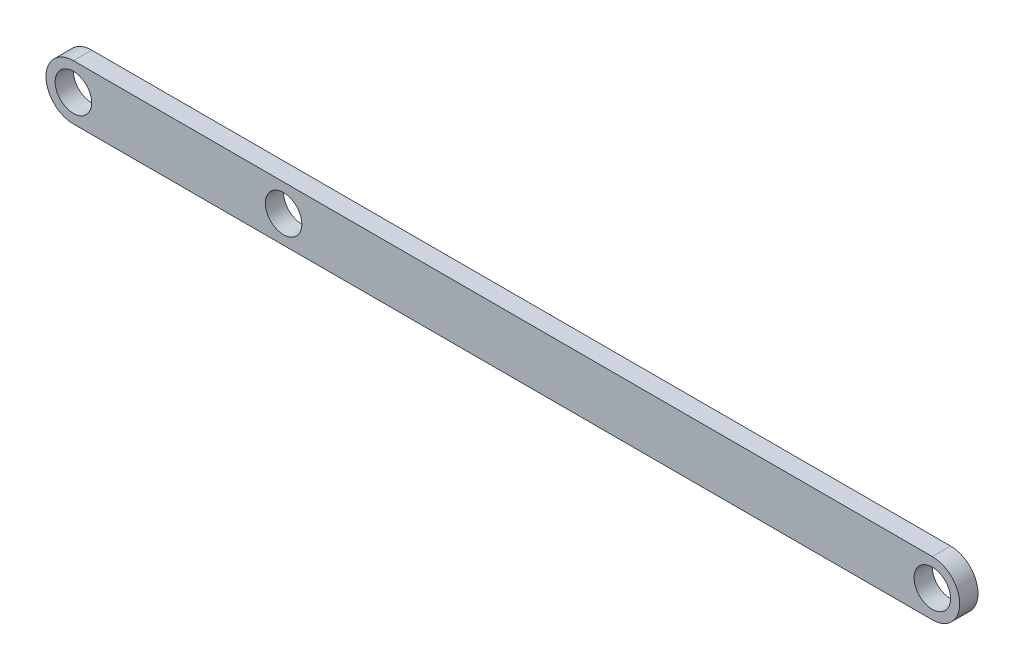
from build123d import *

# Parameters (mm, degrees)
SKETCH3_W           = 250
SKETCH3_H           = 15
BOSS_EXTRUDE4_DEPTH = 5
SKETCH7_R           = 5
CUT_EXTRUDE3_DEPTH  = 5
SKETCH8_R           = 5
CUT_EXTRUDE5_DEPTH  = 6


with BuildPart() as part:
    # Sketch3 → Boss-Extrude4 (new body)
    with BuildSketch(Plane.XY):
        with Locations((-125, 7.5)):
            Rectangle(SKETCH3_W, SKETCH3_H)
    extrude(amount=BOSS_EXTRUDE4_DEPTH)

    # Sketch7 → Cut-Extrude3 (cut)
    with BuildSketch(Plane.XY.offset(5)):
        with BuildLine():
            Line((-242.499999991, 15), (-250, 15))
            Line((-250, 15), (-250, 7.5))
            ThreePointArc((-250, 7.5), (-247.803300856, 12.803300862), (-242.499999991, 15))
        make_face()
        with Locations((-242.5, 7.5)):
            Circle(SKETCH7_R)
        with BuildLine():
            ThreePointArc((-242.5, 0), (-247.803300859, 2.196699141), (-250, 7.5))
            Line((-250, 7.5), (-250, 0))
            Line((-250, 0), (-242.5, 0))
        make_face()
        with BuildLine():
            ThreePointArc((0, 7.5), (-2.196699166, 2.196699116), (-7.50000007, 0))
            Line((-7.50000007, 0), (0, 0))
            Line((0, 0), (0, 7.5))
        make_face()
        with BuildLine():
            Line((0, 15), (-7.5, 15))
            ThreePointArc((-7.5, 15), (-2.196699141, 12.803300859), (0, 7.5))
            Line((0, 7.5), (0, 15))
        make_face()
        with Locations((-7.5, 7.5)):
            Circle(SKETCH7_R)
    extrude(amount=-CUT_EXTRUDE3_DEPTH, mode=Mode.SUBTRACT)

    # Sketch8 → Cut-Extrude5 (cut, through all)
    with BuildSketch(Plane.XY.offset(5)):
        with Locations((-185, 7.5)):
            Circle(SKETCH8_R)
    extrude(amount=-CUT_EXTRUDE5_DEPTH, mode=Mode.SUBTRACT)


solid = part.part
